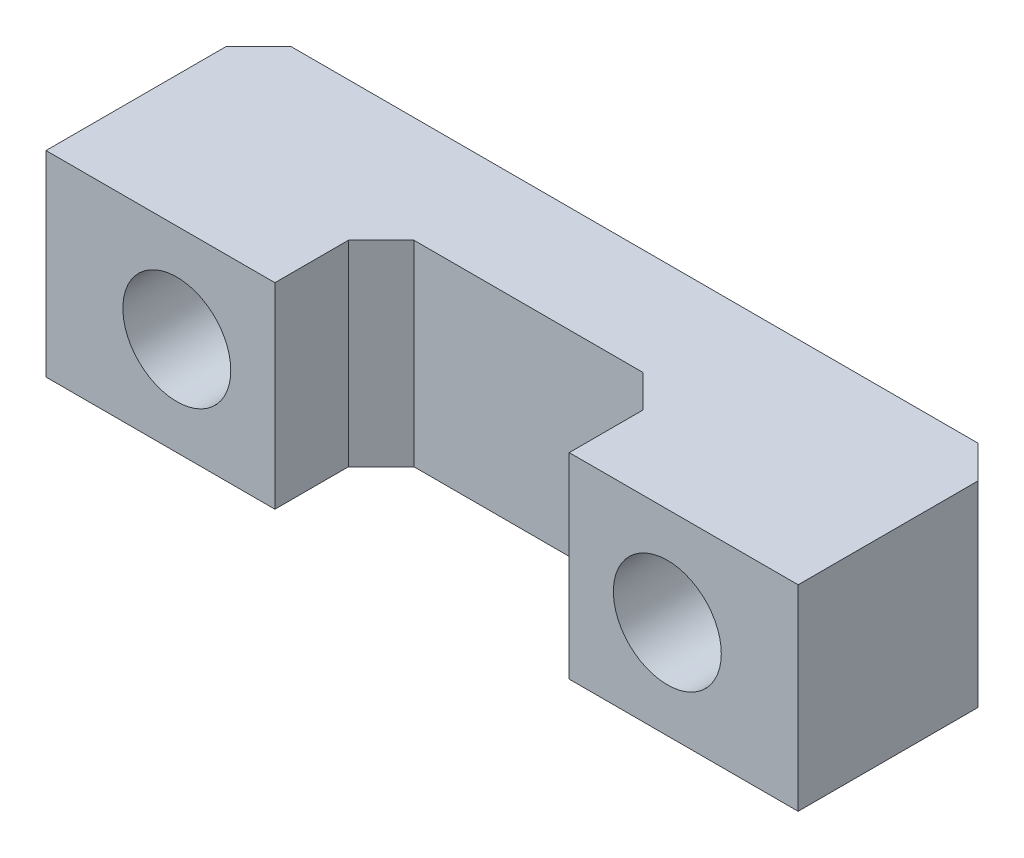
from build123d import *

# Parameters (mm, degrees)
EXTRUDE_1_DEPTH     = 6
SKETCH_2_R          = 1.65
CUT_EXTRUDE_1_DEPTH = 8


with BuildPart() as part:
    # 草图1 → 凸台-拉伸1 (new body)
    with BuildSketch(Plane(origin=(0, 0, 0), x_dir=(1, 0, 0), z_dir=(0, 1, 0))):
        Polygon((-11.5, 0.5), (-11.5, 6), (-10.5, 7), (10.5, 7), (11.5, 6), (11.5, 0.5), (4.5, 0.5), (4.5, 2.75), (3.5, 3.75), (-3.5, 3.75), (-4.5, 2.75), (-4.5, 0.5), align=None)
    extrude(amount=EXTRUDE_1_DEPTH)

    # 草图2 → 切除-拉伸1 (cut)
    with BuildSketch(Plane.XY.offset(-0.5)):
        with Locations((-7.5, 3)):
            Circle(SKETCH_2_R)
        with Locations((7.5, 3)):
            Circle(SKETCH_2_R)
    extrude(amount=-CUT_EXTRUDE_1_DEPTH, mode=Mode.SUBTRACT)


solid = part.part
